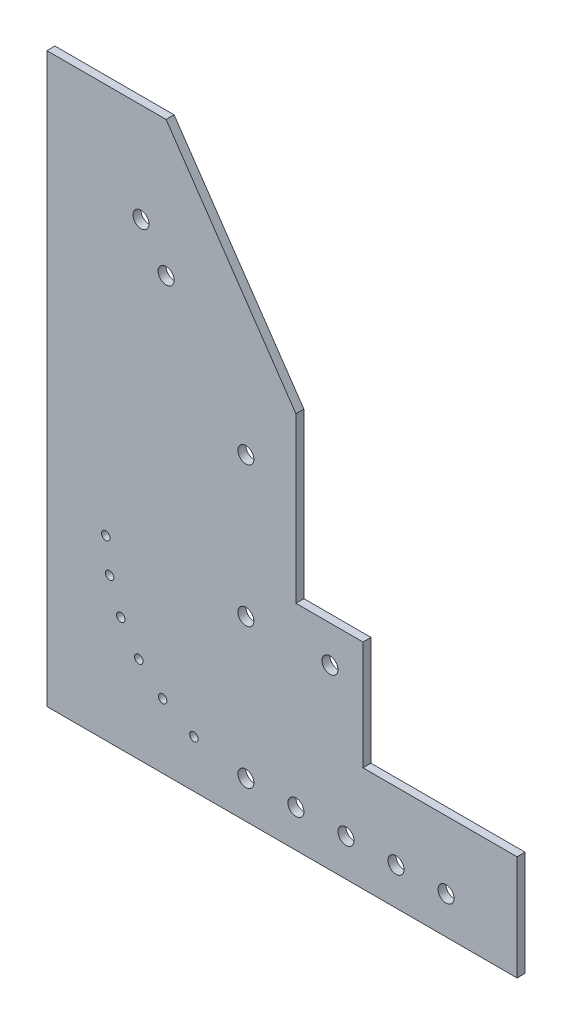
from build123d import *
from build123d.topology import SkipClean

# Parameters (mm, degrees)
SKETCH_2_R          = 2.1
SKETCH_2_R_2        = 4
EXTRUDE_2_DEPTH     = 4
SKETCH_2_4_R        = 2.1
SKETCH_2_4_R_2      = 4
CUT_EXTRUDE_1_DEPTH = 15


with BuildPart() as part:
    # 草图2 → 凸台-拉伸2 (new body)
    with BuildSketch(Plane.XY):
        Polygon((-51.411814067, -23.645961981), (183.493005706, -23.645961981), (183.493005706, 28.798986499), (106.485233254, 28.798986499), (106.485233254, 83.235515302), (73, 83.235515302), (73, 165.222238559), (8.133015227, 260.154233909), (-51.411814067, 260.154233909), align=None)
        with Locations((6.416988046, 8.689671313)):
            Circle(SKETCH_2_R, mode=Mode.SUBTRACT)
        with Locations((-5.491997211, 19.849072718)):
            Circle(SKETCH_2_R, mode=Mode.SUBTRACT)
        with Locations((-14.493242982, 33.462806377)):
            Circle(SKETCH_2_R, mode=Mode.SUBTRACT)
        with BuildLine():
            Line((24.119237886, 0), (22.019237886, 0))
            ThreePointArc((22.019237886, 0), (22.997160887, -0.38239852), (23.980709842, -0.750085173))
            ThreePointArc((23.980709842, -0.750085173), (19.954160272, 0.381384906), (24.119237886, 0))
        make_face(mode=Mode.SUBTRACT)
        with BuildLine():
            ThreePointArc((52, -5), (47.94285131, -8.999591733), (44.001632986, -4.885714286))
            ThreePointArc((44.001632986, -4.885714286), (46, -4.971422738), (48, -5))
            Line((48, -5), (52, -5))
        make_face(mode=Mode.SUBTRACT)
        with Locations((-22, 65)):
            Circle(SKETCH_2_R, mode=Mode.SUBTRACT)
        with Locations((-20.097455932, 48.790851483)):
            Circle(SKETCH_2_R, mode=Mode.SUBTRACT)
        with Locations((48, 65)):
            Circle(SKETCH_2_R_2, mode=Mode.SUBTRACT)
        with BuildLine():
            ThreePointArc((77, -5), (73, -9), (69, -5))
            Line((69, -5), (77, -5))
        make_face(mode=Mode.SUBTRACT)
        with BuildLine():
            ThreePointArc((102, -5), (98, -9), (94, -5))
            Line((94, -5), (102, -5))
        make_face(mode=Mode.SUBTRACT)
        with BuildLine():
            ThreePointArc((127, -5), (123, -9), (119, -5))
            Line((119, -5), (127, -5))
        make_face(mode=Mode.SUBTRACT)
        with Locations((148, -5)):
            Circle(SKETCH_2_R_2, mode=Mode.SUBTRACT)
        with Locations((90, 65)):
            Circle(SKETCH_2_R_2, mode=Mode.SUBTRACT)
        with Locations((48, 135)):
            Circle(SKETCH_2_R_2, mode=Mode.SUBTRACT)
        with BuildLine():
            ThreePointArc((-2.118495143, 207.333508449), (-7.684495307, 208.343281781), (-6.674721974, 213.909281945))
            ThreePointArc((-6.674721974, 213.909281945), (-1.108721811, 212.899508613), (-2.118495143, 207.333508449))
        make_face(mode=Mode.SUBTRACT)
        with Locations((8.133015227, 192.538018085)):
            Circle(SKETCH_2_R_2, mode=Mode.SUBTRACT)
    extrude(amount=EXTRUDE_2_DEPTH)

    # 草图2<4> → 切除-拉伸1 (cut, symmetric)
    with SkipClean():  # the faces are left unmerged after this step: merging them gives an invalid solid
        with BuildSketch(Plane.XY):
            with Locations((6.416988046, 8.689671313)):
                Circle(SKETCH_2_4_R)
            with Locations((-22, 65)):
                Circle(SKETCH_2_4_R)
            with Locations((-14.493242982, 33.462806377)):
                Circle(SKETCH_2_4_R)
            with Locations((22.019237886, 0)):
                Circle(SKETCH_2_4_R)
            with Locations((-20.097455932, 48.790851483)):
                Circle(SKETCH_2_4_R)
            with Locations((-5.491997211, 19.849072718)):
                Circle(SKETCH_2_4_R)
            with Locations((48, -5)):
                Circle(SKETCH_2_4_R_2)
            with Locations((148, -5)):
                Circle(SKETCH_2_4_R_2)
            with Locations((98, -5)):
                Circle(SKETCH_2_4_R_2)
            with Locations((73, -5)):
                Circle(SKETCH_2_4_R_2)
            with Locations((123, -5)):
                Circle(SKETCH_2_4_R_2)
        extrude(amount=CUT_EXTRUDE_1_DEPTH, both=True, mode=Mode.SUBTRACT)


solid = part.part
